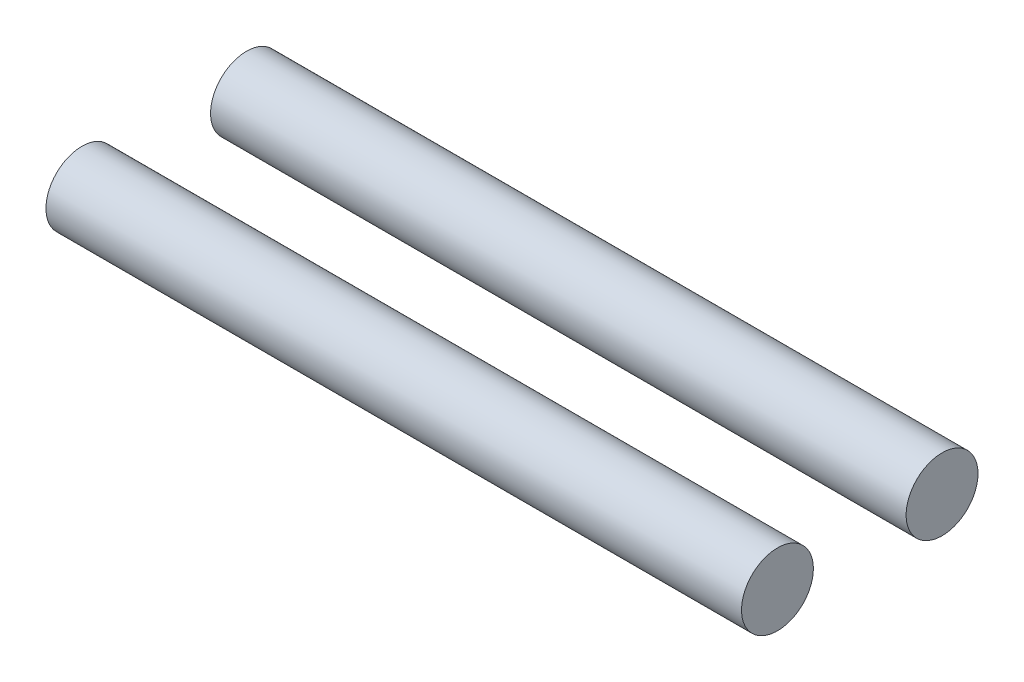
from build123d import *

# Parameters (mm, degrees)
SKETCH_2_R = 1.55


with BuildPart() as part:
    # По траектории1: sweep along a path in Эскиз1
    with BuildLine(Plane.XY) as sweep_1_path:
        Line((0, 0), (-30, 0))
    # Эскиз2 → По траектории1 (sweep)
    with BuildSketch(Plane(origin=(0, 0, 0), x_dir=(0, 0, -1), z_dir=(1, 0, 0))):
        Circle(SKETCH_2_R)
        with Locations((7.1, 0)):
            Circle(SKETCH_2_R)
    sweep(path=sweep_1_path.line)


solid = part.part
